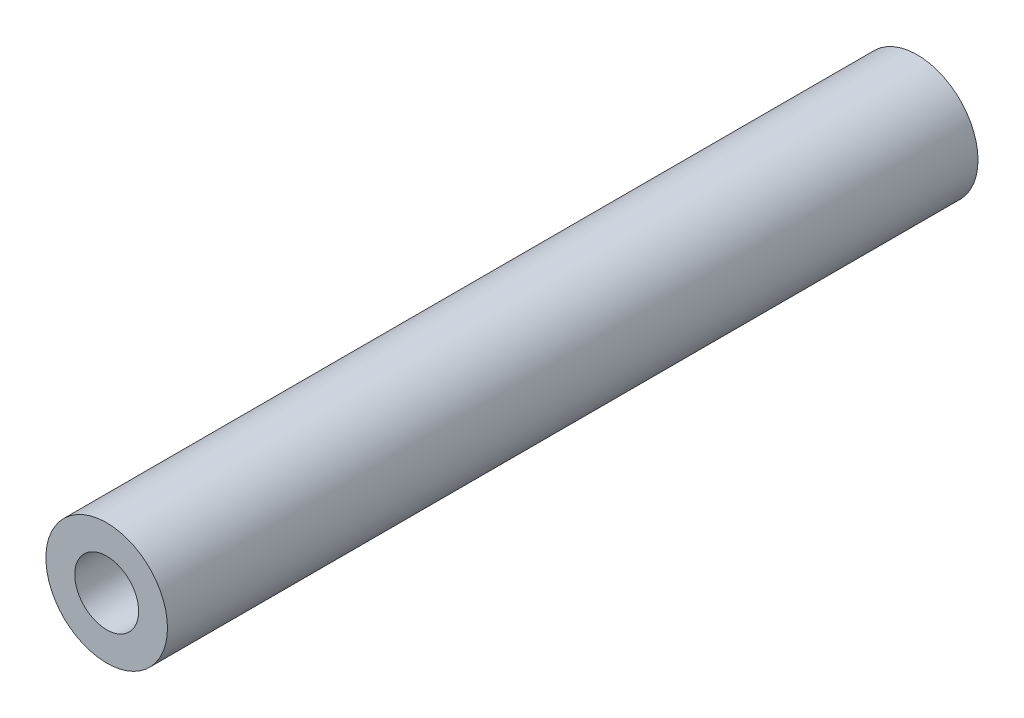
from build123d import *

# Parameters (mm, degrees)
ESBO_O1_R                                  = 3
RESSALTO_EXTRUS_O1_DEPTH                   = 40
BROCA_DE_ROSQUEAR_PARA_HELICOIDE_M31_D     = 3.15
BROCA_DE_ROSQUEAR_PARA_HELICOIDE_M31_DEPTH = 4
BROCA_DE_ROSQUEAR_PARA_HELICOIDE_M31_TIP   = 0.946355475
BROCA_DE_ROSQUEAR_PARA_HELICOIDE_M32_D     = 3.15
BROCA_DE_ROSQUEAR_PARA_HELICOIDE_M32_DEPTH = 4
BROCA_DE_ROSQUEAR_PARA_HELICOIDE_M32_TIP   = 0.946355475


with BuildPart() as part:
    # Esboço1 → Ressalto-extrusão1 (new body)
    with BuildSketch(Plane.XY):
        Circle(ESBO_O1_R)
    extrude(amount=RESSALTO_EXTRUS_O1_DEPTH)

    # Broca de rosquear para helicoide M31
    with Locations(Plane(origin=(0, 0, 0), x_dir=(-1, 0, 0), z_dir=(0, 0, -1))):
        with Locations((0, 0)):
            Hole(BROCA_DE_ROSQUEAR_PARA_HELICOIDE_M31_D / 2, depth=BROCA_DE_ROSQUEAR_PARA_HELICOIDE_M31_DEPTH)
            with Locations((0, 0, -(BROCA_DE_ROSQUEAR_PARA_HELICOIDE_M31_DEPTH + BROCA_DE_ROSQUEAR_PARA_HELICOIDE_M31_TIP / 2))):  # 118° drill point
                Cone(0, BROCA_DE_ROSQUEAR_PARA_HELICOIDE_M31_D / 2, BROCA_DE_ROSQUEAR_PARA_HELICOIDE_M31_TIP, mode=Mode.SUBTRACT)

    # Broca de rosquear para helicoide M32
    with Locations(Plane.XY.offset(40)):
        with Locations((0, 0)):
            Hole(BROCA_DE_ROSQUEAR_PARA_HELICOIDE_M32_D / 2, depth=BROCA_DE_ROSQUEAR_PARA_HELICOIDE_M32_DEPTH)
            with Locations((0, 0, -(BROCA_DE_ROSQUEAR_PARA_HELICOIDE_M32_DEPTH + BROCA_DE_ROSQUEAR_PARA_HELICOIDE_M32_TIP / 2))):  # 118° drill point
                Cone(0, BROCA_DE_ROSQUEAR_PARA_HELICOIDE_M32_D / 2, BROCA_DE_ROSQUEAR_PARA_HELICOIDE_M32_TIP, mode=Mode.SUBTRACT)


solid = part.part
